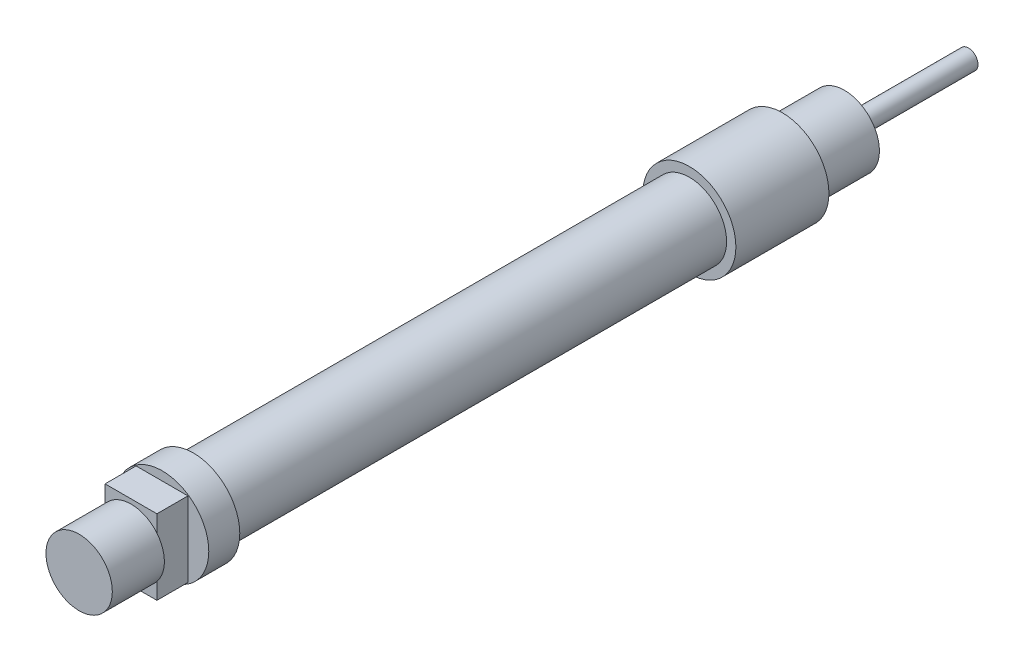
from build123d import *

# Parameters (mm, degrees)
CROQUIS1_R              = 7.5
SALIENTE_EXTRUIR1_DEPTH = 15
CROQUIS2_R              = 6
SALIENTE_EXTRUIR2_DEPTH = 80
CROQUIS4_R              = 7.5
SALIENTE_EXTRUIR3_DEPTH = 5
SALIENTE_EXTRUIR4_DEPTH = 5
CROQUIS7_R              = 5.35
SALIENTE_EXTRUIR6_DEPTH = 8.39
CROQUIS8_R              = 5.641199124
SALIENTE_EXTRUIR7_DEPTH = 10
CROQUIS9_R              = 1.540513395
SALIENTE_EXTRUIR8_DEPTH = 20


with BuildPart() as part:
    # Croquis1 → Saliente-Extruir1 (new body)
    with BuildSketch(Plane.XY):
        with Locations((-11.670259109, 4.990389294)):
            Circle(CROQUIS1_R)
    extrude(amount=SALIENTE_EXTRUIR1_DEPTH)

    # Croquis2 → Saliente-Extruir2 (add)
    with BuildSketch(Plane.XY.offset(15)):
        with Locations((-11.670259109, 4.990389294)):
            Circle(CROQUIS2_R)
    extrude(amount=SALIENTE_EXTRUIR2_DEPTH)

    # Croquis4 → Saliente-Extruir3 (add)
    with BuildSketch(Plane.XY.offset(95)):
        with Locations((-11.658111308, 5.002537095)):
            Circle(CROQUIS4_R)
    extrude(amount=SALIENTE_EXTRUIR3_DEPTH)

    # Croquis5 → Saliente-Extruir4 (add)
    with BuildSketch(Plane.XY.offset(100)):
        Polygon((-7.518768123, 4.990389294), (-7.518768123, 11.066839741), (-15.877144731, 11.066839741), (-15.877144731, -1.023256523), (-7.518768123, -1.023256523), align=None)
    extrude(amount=SALIENTE_EXTRUIR4_DEPTH)

    # Croquis7 → Saliente-Extruir6 (add)
    with BuildSketch(Plane.XY.offset(105)):
        with Locations((-11.670259109, 4.990389294)):
            Circle(CROQUIS7_R)
    extrude(amount=SALIENTE_EXTRUIR6_DEPTH)

    # Croquis8 → Saliente-Extruir7 (add)
    with BuildSketch(Plane(origin=(0, 0, 0), x_dir=(-1, 0, 0), z_dir=(0, 0, -1))):
        with Locations((11.670259109, 4.990389294)):
            Circle(CROQUIS8_R)
    extrude(amount=SALIENTE_EXTRUIR7_DEPTH)

    # Croquis9 → Saliente-Extruir8 (add)
    with BuildSketch(Plane(origin=(0, 0, -10), x_dir=(-1, 0, 0), z_dir=(0, 0, -1))):
        with Locations((11.670259109, 4.990389294)):
            Circle(CROQUIS9_R)
    extrude(amount=SALIENTE_EXTRUIR8_DEPTH)


solid = part.part
